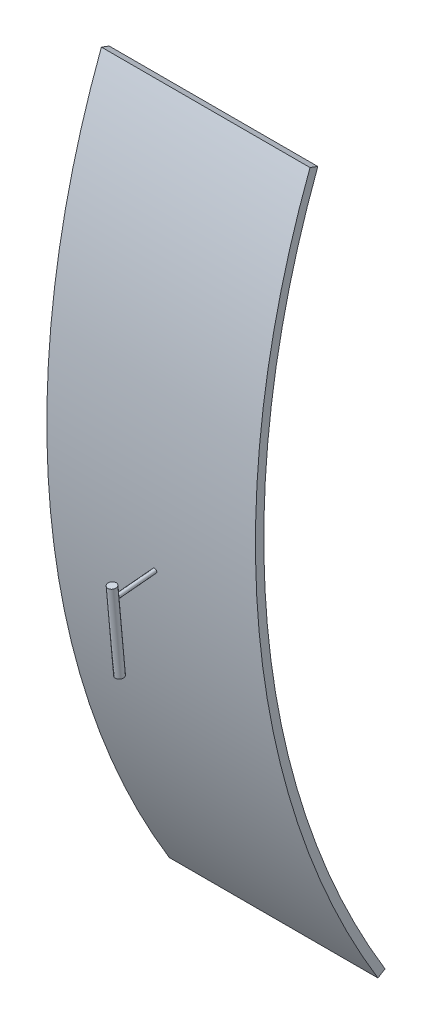
from build123d import *

# Parameters (mm, degrees)
BOSS_EXTRUDE1_DEPTH = 50
SKETCH2_R           = 0.5
BOSS_EXTRUDE2_DEPTH = 10
SKETCH3_W           = 1
SKETCH3_H           = 19.659655446


with BuildPart() as part:
    # Sketch1 → Boss-Extrude1 (new body)
    with BuildSketch(Plane(origin=(0, 0, 0), x_dir=(0, 0, -1), z_dir=(1, 0, 0))):
        with BuildLine():
            Line((-188.92590538, 71.491274126), (-187.055351862, 70.783439729))
            ThreePointArc((-187.055351862, 70.783439729), (-199.153654229, -18.379934904), (-170.940885579, -103.822991854))
            Line((-170.940885579, -103.822991854), (-172.650294434, -104.861221773))
            ThreePointArc((-172.650294434, -104.861221773), (-201.145190772, -18.563734253), (-188.92590538, 71.491274126))
        make_face()
    extrude(amount=BOSS_EXTRUDE1_DEPTH)


with BuildPart() as body_2:
    # Sketch2 → Boss-Extrude2 (new body)
    with BuildSketch(Plane(origin=(0, -18.563734253, 201.145190772), x_dir=(1, 0, 0), z_dir=(0, -0.091899675, 0.995768271))):
        with Locations((25, 0)):
            Circle(SKETCH2_R)
    extrude(amount=BOSS_EXTRUDE2_DEPTH)


with BuildPart() as body_3:
    # Sketch3 → Revolve1 (revolve)
    with BuildSketch(Plane(origin=(0, -19.482730998, 211.102873483), x_dir=(1, 0, 0), z_dir=(0, -0.091899675, 0.995768271))):
        with Locations((25.5, -6.876765449)):
            Rectangle(SKETCH3_W, SKETCH3_H)
    revolve(axis=Axis((25, -16.542165283, 211.374258945), (0, -0.995768271, -0.091899675)))


solid = Compound([part.part, body_2.part, body_3.part])
